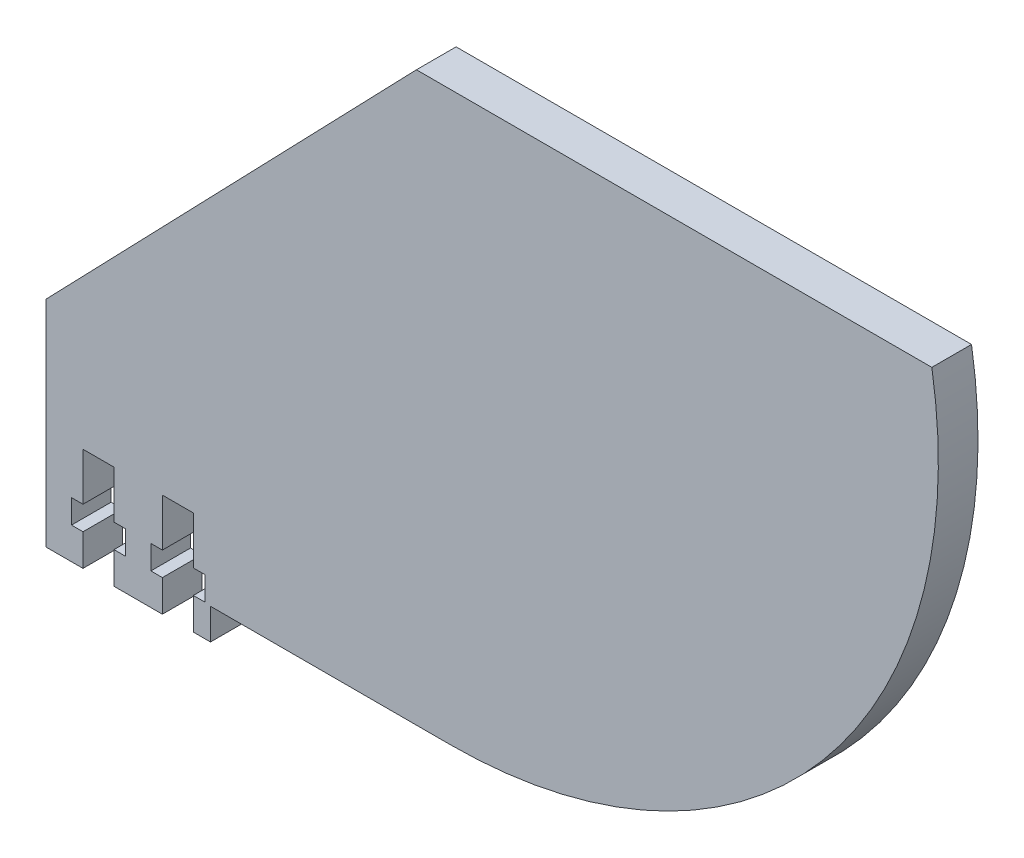
from build123d import *

# Parameters (mm, degrees)
BOSS_EXTRUDE1_DEPTH = 5
CUT_EXTRUDE1_DEPTH  = 5


with BuildPart() as part:
    # Sketch2 → Boss-Extrude1 (new body)
    with BuildSketch(Plane.XY):
        with BuildLine():
            Line((-252.87, -75.4), (-232.15, -75.4))
            Line((-232.15, -75.4), (-232.15, -71.5))
            Line((-232.15, -71.5), (-201.961827551, -71.5))
            ThreePointArc((-201.961827551, -71.5), (-155.072329793, -49.794786091), (-141.280281757, 0))
            Line((-141.280281757, 0), (-206.208901909, 0))
            Line((-206.208901909, 0), (-252.87, -48.35711287))
            Line((-252.87, -48.35711287), (-252.87, -75.4))
        make_face()
    extrude(amount=BOSS_EXTRUDE1_DEPTH)

    # Sketch3 → Cut-Extrude1 (cut)
    with BuildSketch(Plane.XY.offset(5)):
        Polygon((-248.21, -75.4), (-244.31, -75.4), (-244.31, -71.4), (-242.86, -71.4), (-242.86, -68.4), (-244.31, -68.4), (-244.31, -62.4), (-248.21, -62.4), (-248.21, -68.4), (-249.66, -68.4), (-249.66, -71.4), (-248.21, -71.4), align=None)
        Polygon((-238.21, -75.4), (-234.31, -75.4), (-234.31, -71.4), (-232.86, -71.4), (-232.86, -68.4), (-234.31, -68.4), (-234.31, -62.4), (-238.21, -62.4), (-238.21, -68.4), (-239.66, -68.4), (-239.66, -71.4), (-238.21, -71.4), align=None)
    extrude(amount=-CUT_EXTRUDE1_DEPTH, mode=Mode.SUBTRACT)


solid = part.part
